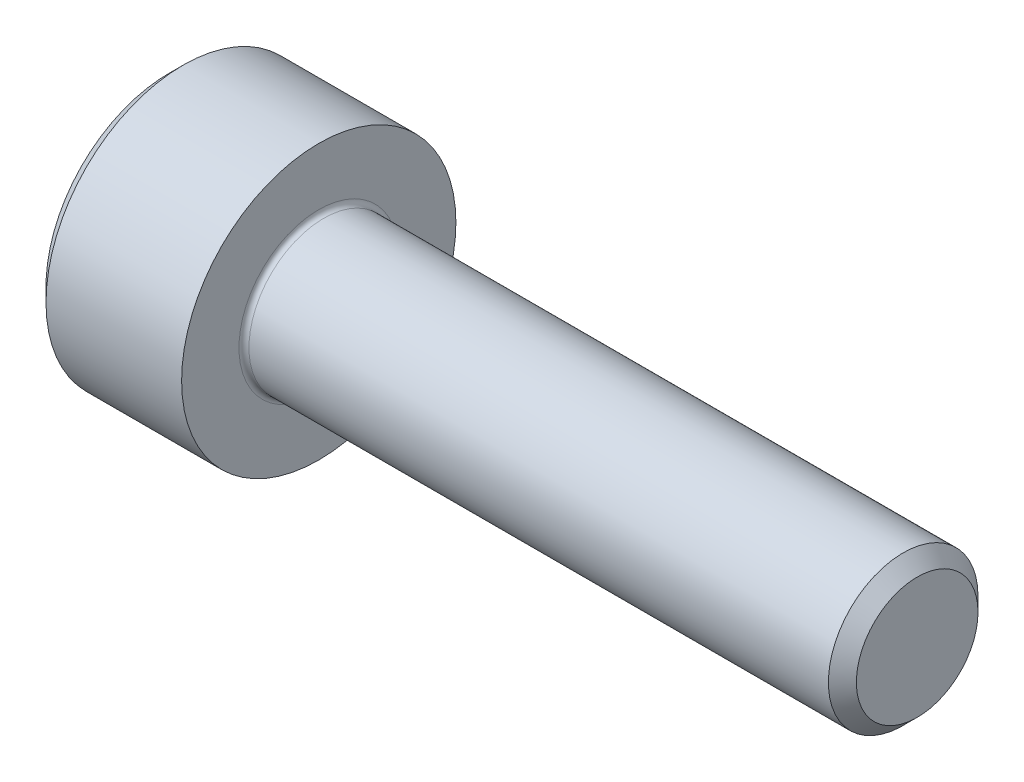
from build123d import *

# Parameters (mm, degrees)
SKETCH1_R           = 2.75
BOSS_EXTRUDE1_DEPTH = 3
CUT_EXTRUDE1_DEPTH  = 1.3
SKETCH9_R           = 1.5
BOSS_EXTRUDE2_DEPTH = 12
CHAMFER1_SIZE       = 0.2805
FILLET1_R           = 0.1


with BuildPart() as part:
    # Sketch1 → Boss-Extrude1 (new body)
    with BuildSketch(Plane(origin=(0, 0, 0), x_dir=(0, -1, 0), z_dir=(-1, 0, 0))):
        Circle(SKETCH1_R)
    extrude(amount=-BOSS_EXTRUDE1_DEPTH)

    # Sketch2 → Cut-Extrude1 (cut)
    with BuildSketch(Plane.ZY):
        Polygon((0, -1.478016689), (1.28, -0.739008345), (1.28, 0.739008345), (0, 1.478016689), (-1.28, 0.739008345), (-1.28, -0.739008345), align=None)
    extrude(amount=-CUT_EXTRUDE1_DEPTH, mode=Mode.SUBTRACT)

    # Sketch4 → Cut-Revolve1 (revolve, cut)
    with BuildSketch(Plane.XY):
        Polygon((1.3, 1.28), (1.3, 0), (2.039008345, 0), align=None)
    revolve(axis=Axis((1.3, 0, 0), (1, 0, 0)), mode=Mode.SUBTRACT)

    # Sketch9 → Boss-Extrude2 (add)
    with BuildSketch(Plane(origin=(3, 0, 0), x_dir=(0, 0, -1), z_dir=(1, 0, 0))):
        Circle(SKETCH9_R)
    extrude(amount=BOSS_EXTRUDE2_DEPTH)

    # Chamfer1
    chamfer1_edges = [part.edges().sort_by_distance(p)[0] for p in [
        (0, 2.75, 0),
        (15, 0, 1.5),
    ]]
    chamfer(chamfer1_edges, length=CHAMFER1_SIZE)

    # Fillet1
    fillet1_edges = [part.edges().sort_by_distance(p)[0] for p in [
        (3, 0, 1.5),
    ]]
    fillet(fillet1_edges, radius=FILLET1_R)


solid = part.part
